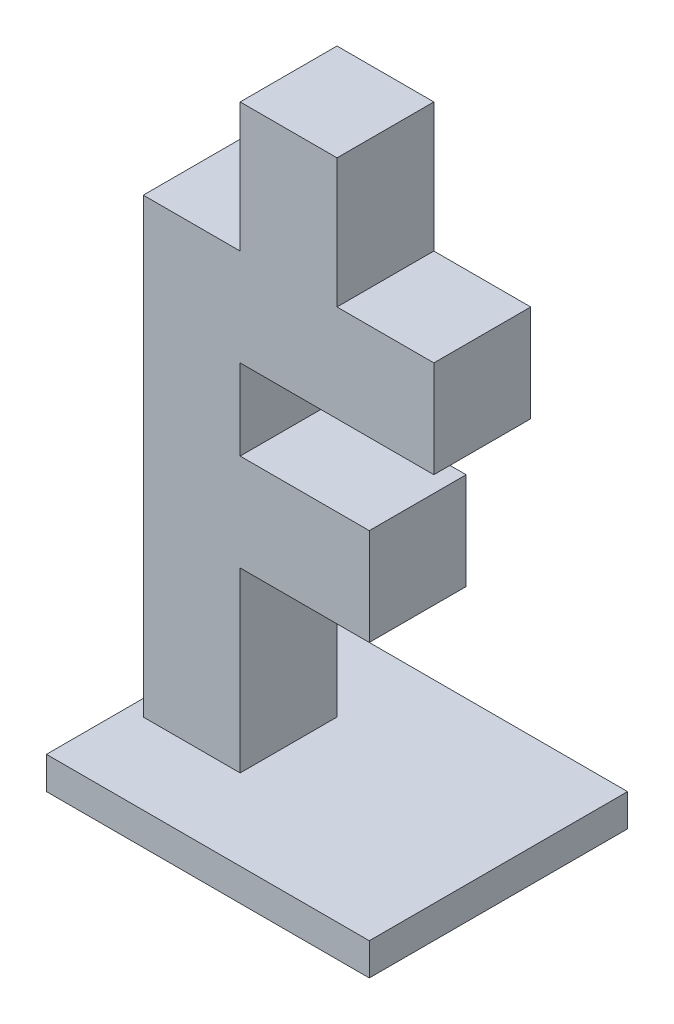
from build123d import *

# Parameters (mm, degrees)
AUFSATZ_LINEAR_AUSTRAGEN1_DEPTH = 15
SKIZZE2_W                       = 50
SKIZZE2_H                       = 40
AUFSATZ_LINEAR_AUSTRAGEN2_DEPTH = 5


with BuildPart() as part:
    # Skizze1 → Aufsatz-Linear austragen1 (new body)
    with BuildSketch(Plane.XY):
        Polygon((0, 0), (0, 70), (15, 70), (15, 90), (30, 90), (30, 70), (45, 70), (45, 55), (15, 55), (15, 42.5), (35, 42.5), (35, 27.5), (15, 27.5), (15, 0), align=None)
    extrude(amount=AUFSATZ_LINEAR_AUSTRAGEN1_DEPTH)

    # Skizze2 → Aufsatz-Linear austragen2 (add)
    with BuildSketch(Plane.XZ):
        with Locations((22.5, 7.5)):
            Rectangle(SKIZZE2_W, SKIZZE2_H)
    extrude(amount=AUFSATZ_LINEAR_AUSTRAGEN2_DEPTH)


solid = part.part
